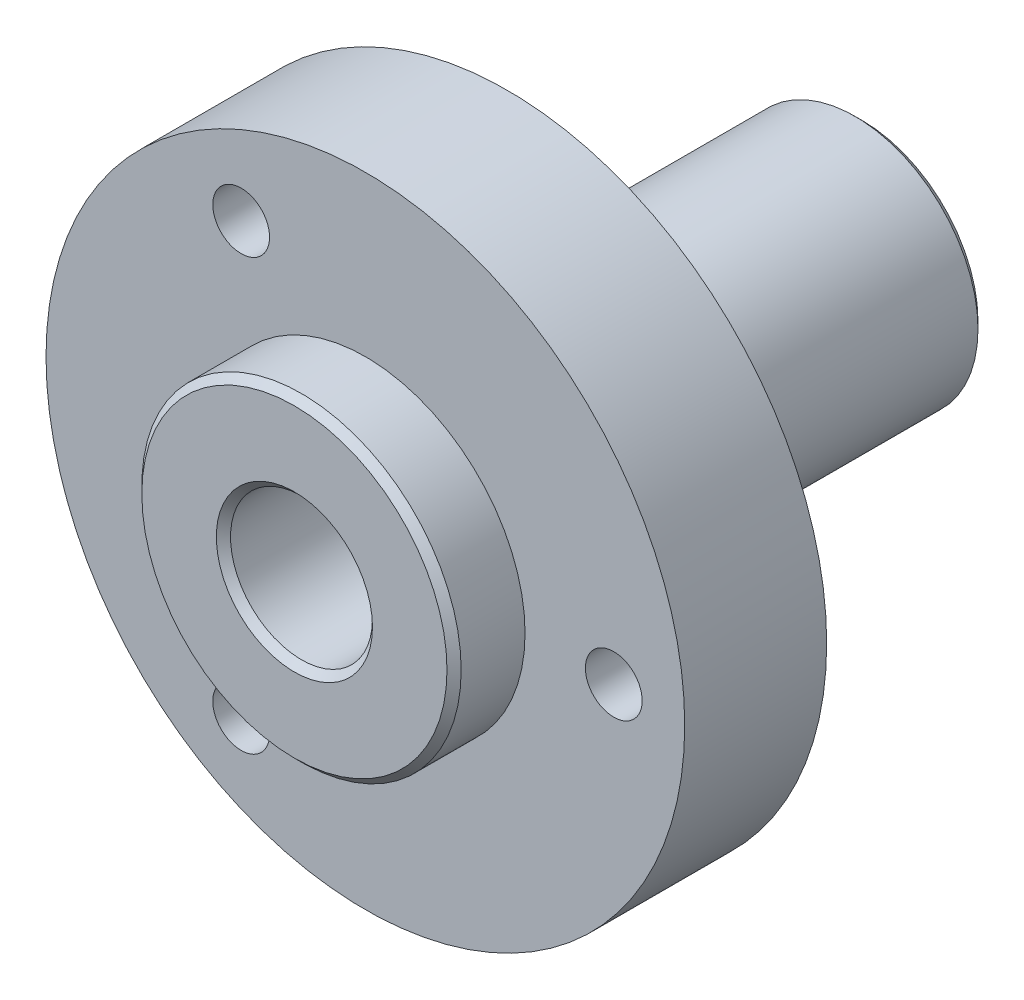
from build123d import *

# Parameters (mm, degrees)
SKETCH1_R             = 4.5
BOSS_EXTRUDE1_DEPTH   = 2
SKETCH2_R             = 9
BOSS_EXTRUDE2_DEPTH   = 4
SKETCH3_R             = 3.463787736
BOSS_EXTRUDE3_DEPTH   = 10
M2X0_4_TAPPED_HOLE1_D = 1.6
SKETCH7_R             = 2
CUT_EXTRUDE3_DEPTH    = 17
CHAMFER1_SIZE         = 0.2


with BuildPart() as part:
    # Sketch1 → Boss-Extrude1 (new body)
    with BuildSketch(Plane.XY):
        Circle(SKETCH1_R)
    extrude(amount=-BOSS_EXTRUDE1_DEPTH)

    # Sketch2 → Boss-Extrude2 (add)
    with BuildSketch(Plane(origin=(0, 0, -2), x_dir=(-1, 0, 0), z_dir=(0, 0, -1))):
        Circle(SKETCH2_R)
    extrude(amount=BOSS_EXTRUDE2_DEPTH)

    # Sketch3 → Boss-Extrude3 (add)
    with BuildSketch(Plane(origin=(0, 0, -6), x_dir=(-1, 0, 0), z_dir=(0, 0, -1))):
        Circle(SKETCH3_R)
    extrude(amount=BOSS_EXTRUDE3_DEPTH)

    # M2x0.4 Tapped Hole1 (through all)
    with Locations(Plane.XY.offset(-2)):
        with Locations((-3.5, 6.062177826), (-3.5, -6.062177826), (7, 0)):
            Hole(M2X0_4_TAPPED_HOLE1_D / 2)

    # Sketch7 → Cut-Extrude3 (cut, through all)
    with BuildSketch(Plane.XY):
        Circle(SKETCH7_R)
    extrude(amount=-CUT_EXTRUDE3_DEPTH, mode=Mode.SUBTRACT)

    # Chamfer1
    chamfer1_edges = [part.edges().sort_by_distance(p)[0] for p in [
        (3.463787736, 0, -16),
        (-4.5, 0, 0),
        (-2, 0, -16),
        (-2, 0, 0),
    ]]
    chamfer(chamfer1_edges, length=CHAMFER1_SIZE)


solid = part.part
